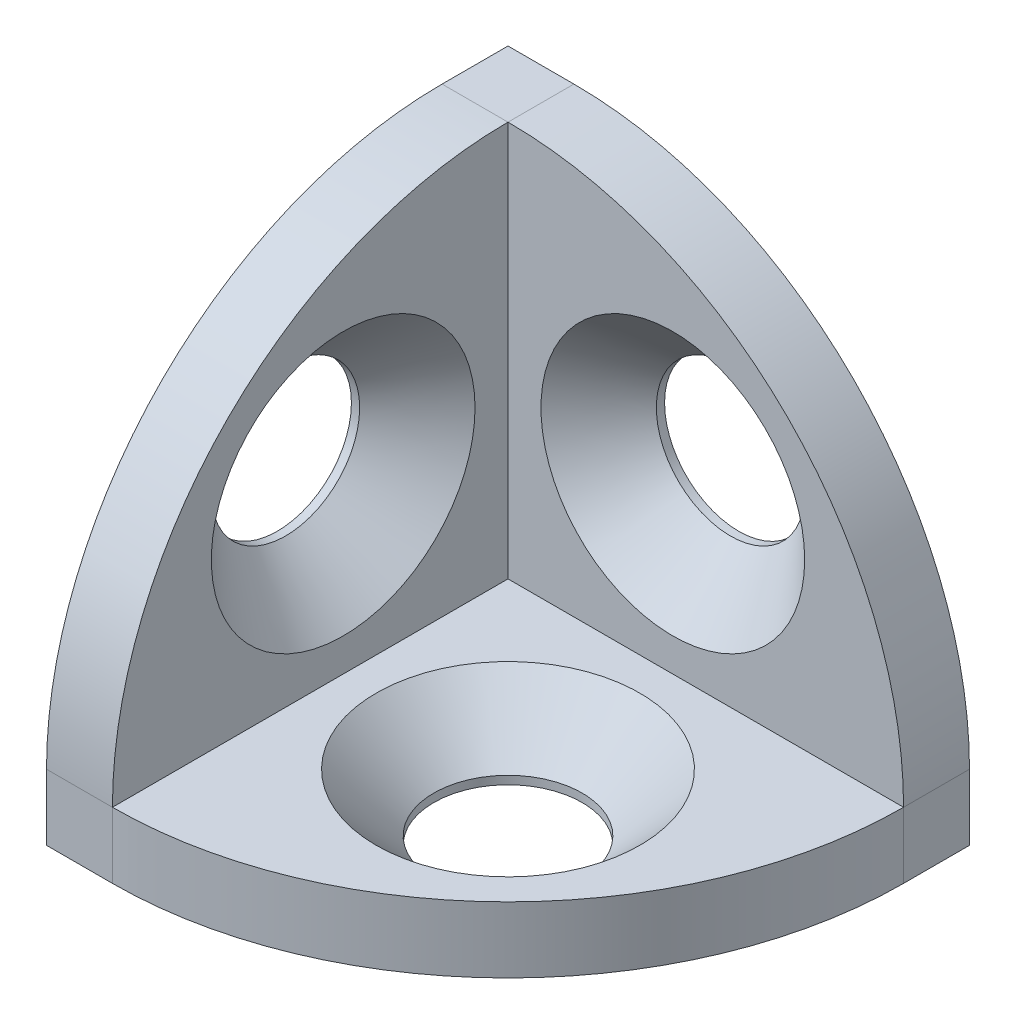
from build123d import *

# Parameters (mm, degrees)
EXTRUDE_1_DEPTH            = 4
SKETCH_4_W                 = 1.5
SKETCH_4_H                 = 8
SKETCH_4_W_2               = 8
SKETCH_4_H_2               = 1.5
EXTRUDE_2_DEPTH            = 1
MIRROR_2_COPY_1_DEPTH      = 4
MIRROR_2_COPY_3_SKETCH_W   = 1.5
MIRROR_2_COPY_3_SKETCH_H   = 8
MIRROR_2_COPY_3_SKETCH_W_2 = 8
MIRROR_2_COPY_3_SKETCH_H_2 = 1.5
MIRROR_2_COPY_3_DEPTH      = 1


with BuildPart() as part:
    # Эскиз1 → Бобышка-Вытянуть1 (new body)
    with BuildSketch(Plane.XY):
        with BuildLine():
            Line((0, 0), (0, 28))
            Line((0, 28), (4, 28))
            ThreePointArc((4, 28), (20.970562748, 20.970562748), (28, 4))
            Line((28, 4), (28, 0))
            Line((28, 0), (0, 0))
        make_face()
    extrude_1 = extrude(amount=EXTRUDE_1_DEPTH)

    # Эскиз3 → Зенковка для винта с полупотайной головкой M81 (revolve, cut)
    with BuildSketch(Plane(origin=(14, 14, 4), x_dir=(0, -1, 0), z_dir=(1, 0, 0))):
        Polygon((0, 0), (0, 11.953872786), (4.5, 9.25), (4.5, 3.5), (8, 0), align=None)
    hole_wizard_m81 = revolve(axis=Axis((14, 14, 10.35), (0, 0, -1)), mode=Mode.SUBTRACT)

    # Эскиз4 → Бобышка-Вытянуть2 (add)
    with BuildSketch(Plane(origin=(0, 0, 0), x_dir=(-1, 0, 0), z_dir=(0, 0, -1))):
        with Locations((-2.25, 14)):
            Rectangle(SKETCH_4_W, SKETCH_4_H)
        with Locations((-14, 2.25)):
            Rectangle(SKETCH_4_W_2, SKETCH_4_H_2)
    extrude_2 = extrude(amount=EXTRUDE_2_DEPTH)

    # Зеркальное отражение1: Бобышка-Вытянуть1, Зенковка для винта с полупотайной головкой M81, Бобышка-Вытянуть2 across plane
    add(extrude_1.mirror(Plane(origin=(0, 0, 0), x_dir=(0, 0.707106781, 0.707106781), z_dir=(0, -0.707106781, 0.707106781))))
    add(hole_wizard_m81.mirror(Plane(origin=(0, 0, 0), x_dir=(0, 0.707106781, 0.707106781), z_dir=(0, -0.707106781, 0.707106781))), mode=Mode.SUBTRACT)
    add(extrude_2.mirror(Plane(origin=(0, 0, 0), x_dir=(0, 0.707106781, 0.707106781), z_dir=(0, -0.707106781, 0.707106781))))

    # Зеркальное отражение2: Бобышка-Вытянуть1, Зенковка для винта с полупотайной головкой M81, Бобышка-Вытянуть2 across plane
    add(extrude_1.mirror(Plane(origin=(0, 0, 0), x_dir=(0.707106781, 0, 0.707106781), z_dir=(-0.707106781, 0, 0.707106781))))
    add(hole_wizard_m81.mirror(Plane(origin=(0, 0, 0), x_dir=(0.707106781, 0, 0.707106781), z_dir=(-0.707106781, 0, 0.707106781))), mode=Mode.SUBTRACT)
    add(extrude_2.mirror(Plane(origin=(0, 0, 0), x_dir=(0.707106781, 0, 0.707106781), z_dir=(-0.707106781, 0, 0.707106781))))

    # Зеркальное отражение2 copy 1 sketch → Зеркальное отражение2 copy 1 (add)
    with BuildSketch(Plane.ZX):
        with BuildLine():
            Line((0, 0), (0, 28))
            Line((0, 28), (4, 28))
            ThreePointArc((4, 28), (20.970562748, 20.970562748), (28, 4))
            Line((28, 4), (28, 0))
            Line((28, 0), (0, 0))
        make_face()
    extrude(amount=MIRROR_2_COPY_1_DEPTH)

    # Зеркальное отражение2 copy 2 sketch → Зеркальное отражение2 copy 2 (revolve, cut)
    with BuildSketch(Plane(origin=(14, 4, 14), x_dir=(-1, 0, 0), z_dir=(0, 0, 1))):
        Polygon((0, 0), (0, 11.953872786), (4.5, 9.25), (4.5, 3.5), (8, 0), align=None)
    revolve(axis=Axis((14, 10.35, 14), (0, -1, 0)), mode=Mode.SUBTRACT)

    # Зеркальное отражение2 copy 3 sketch → Зеркальное отражение2 copy 3 (add)
    with BuildSketch(Plane(origin=(0, 0, 0), x_dir=(0, 0, -1), z_dir=(0, -1, 0))):
        with Locations((-2.25, 14)):
            Rectangle(MIRROR_2_COPY_3_SKETCH_W, MIRROR_2_COPY_3_SKETCH_H)
        with Locations((-14, 2.25)):
            Rectangle(MIRROR_2_COPY_3_SKETCH_W_2, MIRROR_2_COPY_3_SKETCH_H_2)
    extrude(amount=MIRROR_2_COPY_3_DEPTH)


solid = part.part
